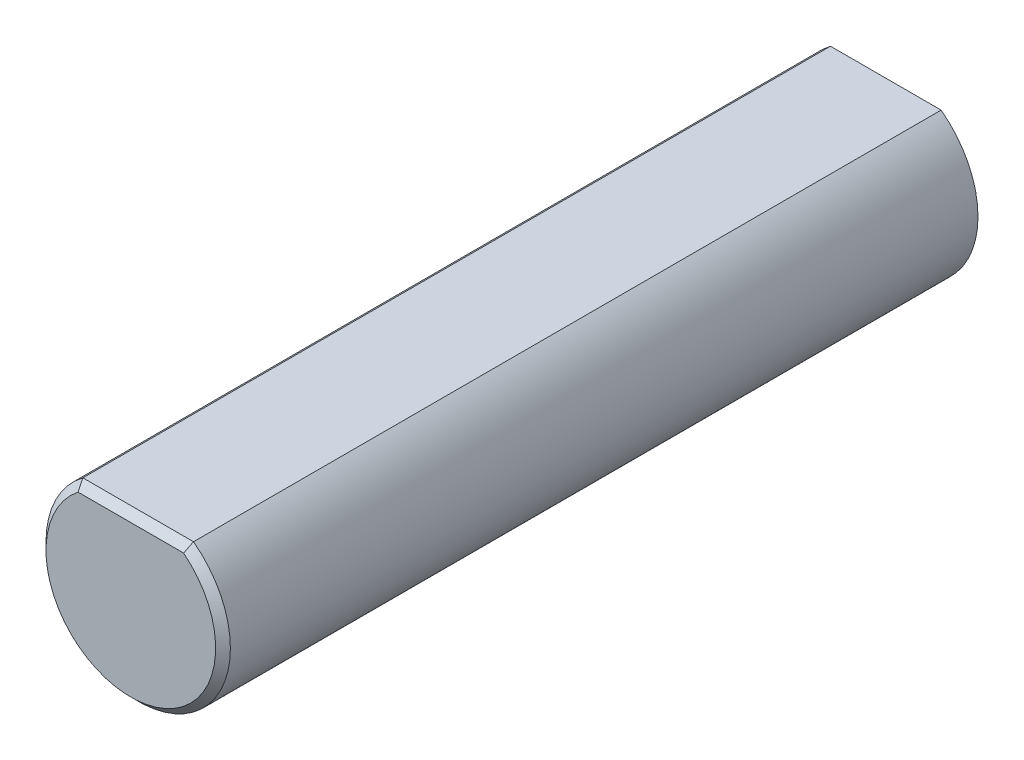
from build123d import *

# Parameters (mm, degrees)
BOSS_EXTRUDE1_DEPTH = 26
CHAMFER1_SIZE       = 0.254


with BuildPart() as part:
    # Sketch1 → Boss-Extrude1 (new body)
    with BuildSketch(Plane.XY):
        with BuildLine():
            Line((1.905, 2.54), (-1.905, 2.54))
            ThreePointArc((-1.905, 2.54), (0, -3.175), (1.905, 2.54))
        make_face()
    extrude(amount=BOSS_EXTRUDE1_DEPTH)

    # Chamfer1
    chamfer1_edges = [part.edges().sort_by_distance(p)[0] for p in [
        (0, -3.175, 26),
        (0, 2.54, 26),
    ]]
    chamfer(chamfer1_edges, length=CHAMFER1_SIZE)


solid = part.part
